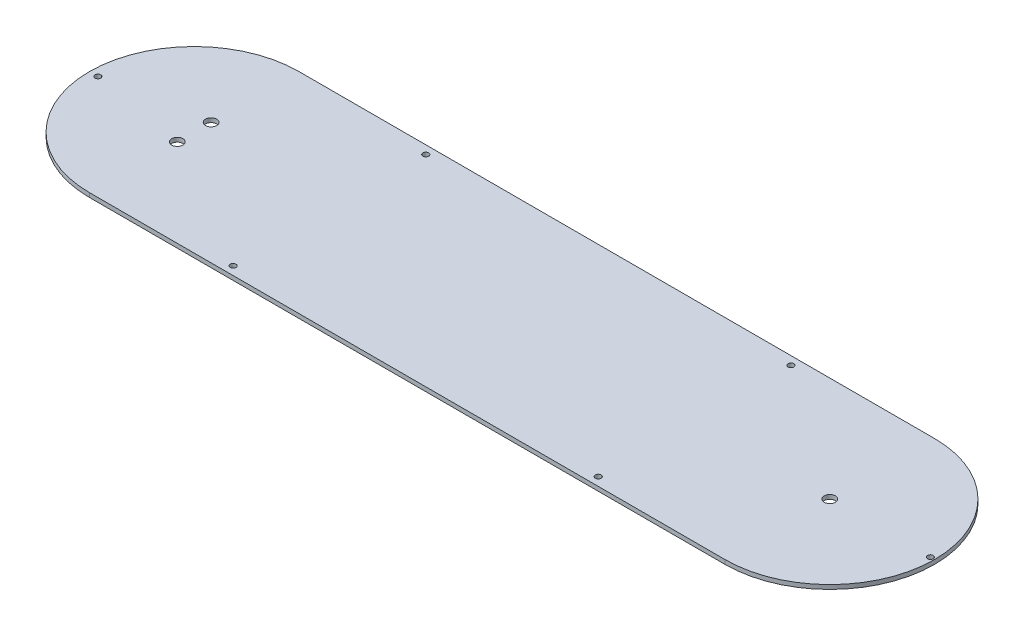
from build123d import *

# Parameters (mm, degrees)
SKETCH1_R           = 1.0922
SKETCH1_R_2         = 2.1
BOSS_EXTRUDE1_DEPTH = 1.5875


with BuildPart() as part:
    # Sketch1 → Boss-Extrude1 (new body)
    with BuildSketch(Plane(origin=(0, 0, 0), x_dir=(1, 0, 0), z_dir=(0, 1, 0))):
        with BuildLine():
            Line((0, 39.37), (238.76, 39.37))
            ThreePointArc((238.76, 39.37), (278.13, 0), (238.76, -39.37))
            Line((238.76, -39.37), (0, -39.37))
            ThreePointArc((0, -39.37), (-39.37, 0), (0, 39.37))
        make_face()
        with Locations((50.8, 36.195)):
            Circle(SKETCH1_R, mode=Mode.SUBTRACT)
        with Locations((187.96, 36.195)):
            Circle(SKETCH1_R, mode=Mode.SUBTRACT)
        with Locations((50.8, -36.195)):
            Circle(SKETCH1_R, mode=Mode.SUBTRACT)
        with Locations((187.96, -36.195)):
            Circle(SKETCH1_R, mode=Mode.SUBTRACT)
        with Locations((-36.195, 0)):
            Circle(SKETCH1_R, mode=Mode.SUBTRACT)
        with Locations((276.5425, 0)):
            Circle(SKETCH1_R, mode=Mode.SUBTRACT)
        with Locations((238.76, 0)):
            Circle(SKETCH1_R_2, mode=Mode.SUBTRACT)
        with Locations((0, -6.35)):
            Circle(SKETCH1_R_2, mode=Mode.SUBTRACT)
        with Locations((0, 6.35)):
            Circle(SKETCH1_R_2, mode=Mode.SUBTRACT)
    extrude(amount=BOSS_EXTRUDE1_DEPTH)


solid = part.part
